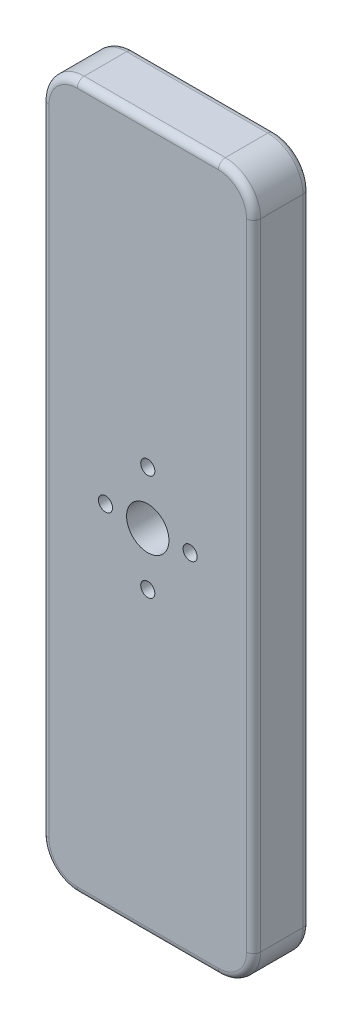
from build123d import *

# Parameters (mm, degrees)
EXTRUDE_1_DEPTH          = 8
SKETCH_2_R               = 3
CUT_EXTRUDE_1_DEPTH      = 3
CUT_EXTRUDE_2_DEPTH      = 3
PATTERN_CIRCULAR_1_COUNT = 8
CUT_EXTRUDE_3_DEPTH      = 3
CUT_EXTRUDE_4_DEPTH      = 3
PATTERN_LINEAR_2_COUNT   = 2
PATTERN_LINEAR_2_PITCH   = 4
PATTERN_LINEAR_4_COUNT   = 2
PATTERN_LINEAR_4_PITCH   = 4
SKETCH_14_R              = 9
CUT_EXTRUDE_7_DEPTH      = 2
SKETCH_15_R              = 3
CUT_EXTRUDE_8_DEPTH      = 7
SKETCH1_R                = 1
CUT_EXTRUDE1_DEPTH       = 7
CIRPATTERN1_COUNT        = 2
SKETCH2_R                = 1
CUT_EXTRUDE2_DEPTH       = 7
CIRPATTERN2_COUNT        = 2
FILLET1_R                = 1
FILLET2_R                = 1


with BuildPart() as part:
    # ｽｹｯﾁ1 → ﾎﾞｽ - 押し出し1 (new body)
    with BuildSketch(Plane.XY):
        with BuildLine():
            Line((5, 0), (25, 0))
            ThreePointArc((25, 0), (28.535533906, 1.464466094), (30, 5))
            Line((30, 5), (30, 95))
            ThreePointArc((30, 95), (28.535533906, 98.535533906), (25, 100))
            Line((25, 100), (5, 100))
            ThreePointArc((5, 100), (1.464466094, 98.535533906), (0, 95))
            Line((0, 95), (0, 5))
            ThreePointArc((0, 5), (1.464466094, 1.464466094), (5, 0))
        make_face()
    extrude(amount=EXTRUDE_1_DEPTH)

    # ｽｹｯﾁ2 → ｶｯﾄ - 押し出し1 (cut)
    with BuildSketch(Plane(origin=(0, 0, 0), x_dir=(-1, 0, 0), z_dir=(0, 0, -1))):
        with Locations((-15, 88)):
            Circle(SKETCH_2_R)
    extrude(amount=-CUT_EXTRUDE_1_DEPTH, mode=Mode.SUBTRACT)

    # ｽｹｯﾁ4 → ｶｯﾄ - 押し出し2 (cut)
    with BuildSketch(Plane(origin=(0, 0, 0), x_dir=(-1, 0, 0), z_dir=(0, 0, -1))):
        with BuildLine():
            Line((-14.25, 95), (-14.25, 93))
            ThreePointArc((-14.25, 93), (-15, 92.25), (-15.75, 93))
            Line((-15.75, 93), (-15.75, 95))
            ThreePointArc((-15.75, 95), (-15, 95.75), (-14.25, 95))
        make_face()
    cut_extrude_2 = extrude(amount=-CUT_EXTRUDE_2_DEPTH, mode=Mode.SUBTRACT)

    # 円形ﾊﾟﾀｰﾝ1: ｶｯﾄ - 押し出し2 ×8 about axis
    pattern_circular_1_axis = Axis((15, 88, 0), (0, 0, 1))
    for i in range(1, PATTERN_CIRCULAR_1_COUNT):
        add(cut_extrude_2.rotate(pattern_circular_1_axis, i * 360 / PATTERN_CIRCULAR_1_COUNT), mode=Mode.SUBTRACT)

    # ｽｹｯﾁ6 → ｶｯﾄ - 押し出し3 (cut)
    with BuildSketch(Plane(origin=(0, 0, 0), x_dir=(-1, 0, 0), z_dir=(0, 0, -1))):
        with BuildLine():
            Line((-9.000000044, 13.498973843), (-21, 13.5))
            ThreePointArc((-21, 13.5), (-23.5, 11), (-21, 8.5))
            ThreePointArc((-21, 8.5), (-19.822875656, 6.378679656), (-17.4, 6.255005568))
            ThreePointArc((-17.4, 6.255005568), (-12.337609323, 4.152719481), (-9.000000117, 8.501026157))
            ThreePointArc((-9.000000117, 8.501026157), (-6.501026157, 10.999999963), (-9.000000044, 13.498973843))
        make_face()
    extrude(amount=-CUT_EXTRUDE_3_DEPTH, mode=Mode.SUBTRACT)

    # ｽｹｯﾁ12 → ｶｯﾄ - 押し出し4 (cut)
    with BuildSketch(Plane(origin=(0, 0, 0), x_dir=(-1, 0, 0), z_dir=(0, 0, -1))):
        with BuildLine():
            Line((-15.258974596, 18.082531755), (-14.008974596, 15.917468245))
            ThreePointArc((-14.008974596, 15.917468245), (-14.375, 14.551442841), (-15.741025404, 14.917468245))
            Line((-15.741025404, 14.917468245), (-16.991025404, 17.082531755))
            ThreePointArc((-16.991025404, 17.082531755), (-16.625, 18.448557159), (-15.258974596, 18.082531755))
        make_face()
    cut_extrude_4 = extrude(amount=-CUT_EXTRUDE_4_DEPTH, mode=Mode.SUBTRACT)

    # 直線ﾊﾟﾀｰﾝ2: ｶｯﾄ - 押し出し4 ×2
    with Locations(*[(-i * PATTERN_LINEAR_2_PITCH, 0, 0) for i in range(1, PATTERN_LINEAR_2_COUNT)]):
        add(cut_extrude_4, mode=Mode.SUBTRACT)

    # 直線ﾊﾟﾀｰﾝ4: ｶｯﾄ - 押し出し4 ×2
    with Locations(*[(i * PATTERN_LINEAR_4_PITCH, 0, 0) for i in range(1, PATTERN_LINEAR_4_COUNT)]):
        add(cut_extrude_4, mode=Mode.SUBTRACT)

    # ｽｹｯﾁ14 → ｶｯﾄ - 押し出し7 (cut)
    with BuildSketch(Plane(origin=(0, 0, 0), x_dir=(-1, 0, 0), z_dir=(0, 0, -1))):
        with Locations((-15, 50)):
            Circle(SKETCH_14_R)
    extrude(amount=-CUT_EXTRUDE_7_DEPTH, mode=Mode.SUBTRACT)

    # ｽｹｯﾁ15 → ｶｯﾄ - 押し出し8 (cut, through all)
    with BuildSketch(Plane(origin=(0, 0, 2), x_dir=(-1, 0, 0), z_dir=(0, 0, -1))):
        with Locations((-15, 50)):
            Circle(SKETCH_15_R)
    extrude(amount=-CUT_EXTRUDE_8_DEPTH, mode=Mode.SUBTRACT)

    # Sketch1 → Cut-Extrude1 (cut, through all)
    with BuildSketch(Plane(origin=(0, 0, 2), x_dir=(-1, 0, 0), z_dir=(0, 0, -1))):
        with Locations((-15, 57.5)):
            Circle(SKETCH1_R)
    cut_extrude1 = extrude(amount=-CUT_EXTRUDE1_DEPTH, mode=Mode.SUBTRACT)

    # CirPattern1: Cut-Extrude1 ×2 about axis
    cirpattern1_axis = Axis((15, 50, 0), (0, 0, 1))
    for i in range(1, CIRPATTERN1_COUNT):
        add(cut_extrude1.rotate(cirpattern1_axis, i * 360 / CIRPATTERN1_COUNT), mode=Mode.SUBTRACT)

    # Sketch2 → Cut-Extrude2 (cut, through all)
    with BuildSketch(Plane(origin=(0, 0, 2), x_dir=(-1, 0, 0), z_dir=(0, 0, -1))):
        with Locations((-21, 50)):
            Circle(SKETCH2_R)
    cut_extrude2 = extrude(amount=-CUT_EXTRUDE2_DEPTH, mode=Mode.SUBTRACT)

    # CirPattern2: Cut-Extrude2 ×2 about axis
    cirpattern2_axis = Axis((15, 50, 0), (0, 0, 1))
    for i in range(1, CIRPATTERN2_COUNT):
        add(cut_extrude2.rotate(cirpattern2_axis, i * 360 / CIRPATTERN2_COUNT), mode=Mode.SUBTRACT)

    # Fillet1
    fillet1_edges = [part.edges().sort_by_distance(p)[0] for p in [
        (28.535533906, 98.535533906, 8),
        (15, 100, 8),
        (1.464466094, 98.535533906, 8),
        (0, 50, 8),
        (1.464466094, 1.464466094, 8),
        (15, 0, 8),
        (28.535533906, 1.464466094, 8),
        (30, 50, 8),
    ]]
    fillet(fillet1_edges, radius=FILLET1_R)

    # Fillet2
    fillet2_edges = [part.edges().sort_by_distance(p)[0] for p in [
        (15, 100, 0),
        (28.535533906, 98.535533906, 0),
        (30, 50, 0),
        (28.535533906, 1.464466094, 0),
        (15, 0, 0),
        (1.464466094, 1.464466094, 0),
        (0, 50, 0),
        (1.464466094, 98.535533906, 0),
    ]]
    fillet(fillet2_edges, radius=FILLET2_R)


solid = part.part
